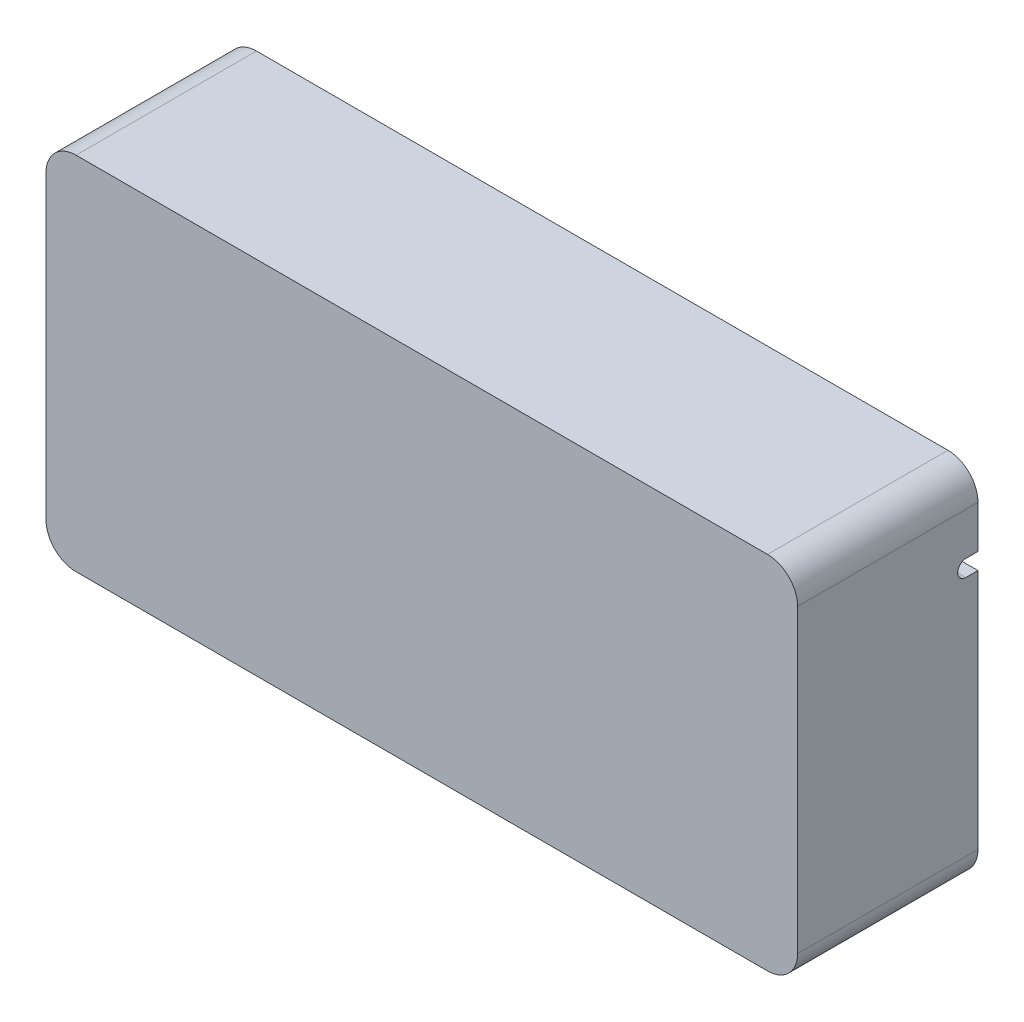
from build123d import *

# Parameters (mm, degrees)
SKETCH1_W           = 317.5
SKETCH1_H           = 152.4
BOSS_EXTRUDE1_DEPTH = 76.2
SKETCH2_W           = 302.26
SKETCH2_H           = 137.16
CUT_EXTRUDE1_DEPTH  = 68.58
CUT_EXTRUDE2_REACH  = 319.5
BOSS_EXTRUDE2_DEPTH = 25.4
CUT_EXTRUDE3_REACH  = 9.62
SKETCH7_R           = 3
BOSS_EXTRUDE4_DEPTH = 7.62
FILLET2_R           = 12.7
FILLET3_R           = 2.54


with BuildPart() as part:
    # Sketch1 → Boss-Extrude1 (new body)
    with BuildSketch(Plane.XY):
        Rectangle(SKETCH1_W, SKETCH1_H)
    extrude(amount=BOSS_EXTRUDE1_DEPTH)

    # Sketch2 → Cut-Extrude1 (cut)
    with BuildSketch(Plane(origin=(0, 0, 0), x_dir=(-1, 0, 0), z_dir=(0, 0, -1))):
        Rectangle(SKETCH2_W, SKETCH2_H)
    extrude(amount=-CUT_EXTRUDE1_DEPTH, mode=Mode.SUBTRACT)

    # Sketch3 → Cut-Extrude2 (cut, up to next)
    with BuildSketch(Plane.ZY.offset(158.75), mode=Mode.PRIVATE) as cut_extrude2_sk1:
        with BuildLine():
            Line((42.037, 38.5445), (0, 38.5445))
            Line((0, 38.5445), (0, 45.5295))
            Line((0, 45.5295), (42.037, 45.5295))
            ThreePointArc((42.037, 45.5295), (45.5295, 42.037), (42.037, 38.5445))
        make_face()
    cut_extrude2_tool1 = extrude(cut_extrude2_sk1.sketch, amount=-CUT_EXTRUDE2_REACH, mode=Mode.PRIVATE) & part.part
    add(cut_extrude2_tool1.solids().sort_by_distance((-158.75, 42.037, 22.396786))[0], mode=Mode.SUBTRACT)

    # Sketch4 → Boss-Extrude2 (add)
    with BuildSketch(Plane(origin=(0, 0, 68.58), x_dir=(-1, 0, 0), z_dir=(0, 0, -1))):
        Polygon((-151.13, 0), (0, 0), (0, -68.58), (-7.112, -68.58), (-7.112, -6.35), (-151.13, -6.35), align=None)
    extrude(amount=BOSS_EXTRUDE2_DEPTH)

    # Sketch5 → Cut-Extrude3 (cut, up to next)
    with BuildSketch(Plane.ZY.offset(-151.13), mode=Mode.PRIVATE) as cut_extrude3_sk1:
        with BuildLine():
            Line((5.08, 38.5445), (0, 38.5445))
            Line((0, 38.5445), (0, 45.5295))
            Line((0, 45.5295), (5.08, 45.5295))
            ThreePointArc((5.08, 45.5295), (8.5725, 42.037), (5.08, 38.5445))
        make_face()
    cut_extrude3_tool1 = extrude(cut_extrude3_sk1.sketch, amount=-CUT_EXTRUDE3_REACH, mode=Mode.PRIVATE) & part.part
    add(cut_extrude3_tool1.solids().sort_by_distance((151.13, 42.037, 3.950338))[0], mode=Mode.SUBTRACT)

    # Sketch7 → Boss-Extrude4 (add)
    with BuildSketch(Plane(origin=(0, 0, 68.58), x_dir=(-1, 0, 0), z_dir=(0, 0, -1))):
        with Locations((140.01, -63.81)):
            Circle(SKETCH7_R)
        with Locations((82.01, -63.81)):
            Circle(SKETCH7_R)
        with Locations((140.01, -14.81)):
            Circle(SKETCH7_R)
        with Locations((82.01, -14.81)):
            Circle(SKETCH7_R)
    extrude(amount=BOSS_EXTRUDE4_DEPTH)

    # Fillet2
    fillet2_edges = [part.edges().sort_by_distance(p)[0] for p in [
        (-151.13, 68.58, 34.29),
        (151.13, 68.58, 34.29),
        (151.13, -68.58, 34.29),
        (-151.13, -68.58, 34.29),
        (-158.75, 76.2, 38.1),
        (158.75, 76.2, 38.1),
        (158.75, -76.2, 38.1),
        (-158.75, -76.2, 38.1),
    ]]
    fillet(fillet2_edges, radius=FILLET2_R)

    # Fillet3
    fillet3_edges = [part.edges().sort_by_distance(p)[0] for p in [
        (151.13, 0, 55.88),
        (151.13, -6.35, 55.88),
        (7.112, -6.35, 55.88),
        (7.112, -68.58, 55.88),
        (0, -68.58, 55.88),
        (0, 0, 55.88),
        (151.13, -3.175, 43.18),
        (3.556, -68.58, 43.18),
    ]]
    fillet(fillet3_edges, radius=FILLET3_R)


solid = part.part
